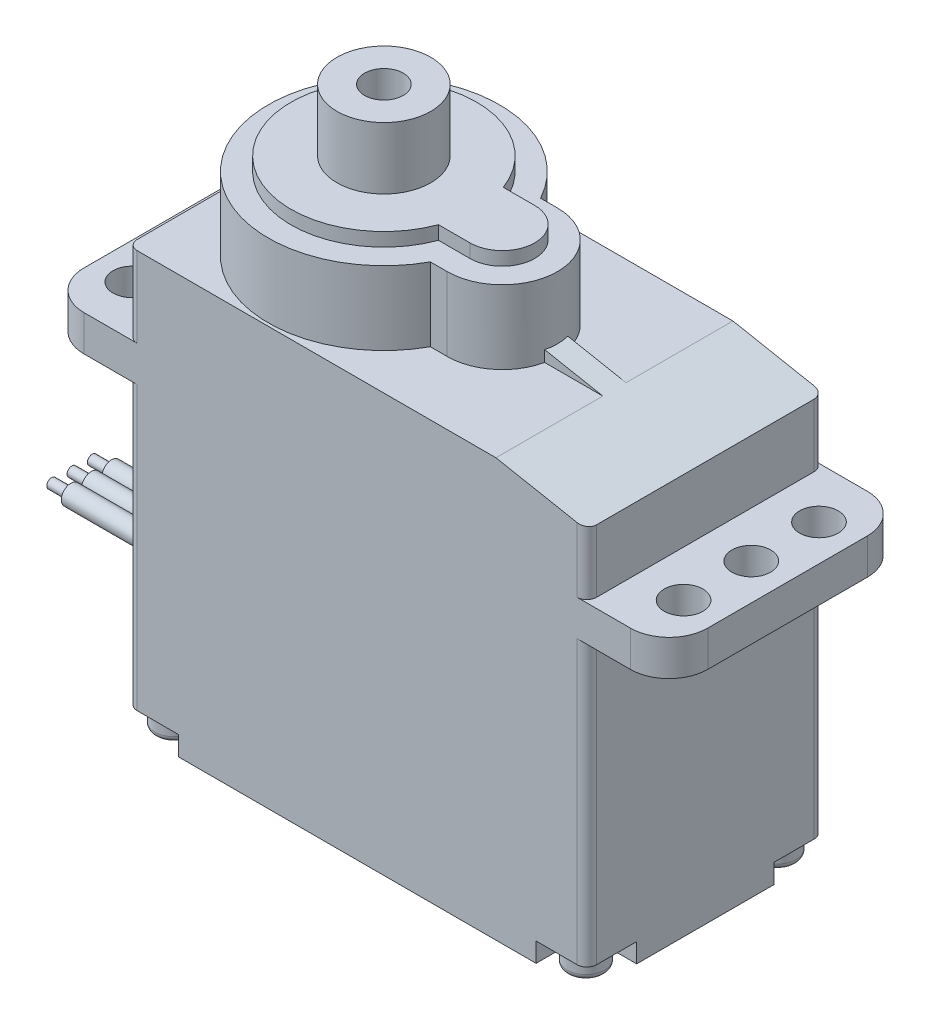
from build123d import *

# Parameters (mm, degrees)
BOSS_EXTRUDE1_DEPTH = 6.125
BOSS_EXTRUDE2_DEPTH = 3.8
BOSS_EXTRUDE3_DEPTH = 0.7
SKETCH4_R           = 1
CUT_EXTRUDE1_DEPTH  = 27.766257209
SKETCH5_R           = 0.975
CUT_EXTRUDE2_DEPTH  = 1
SKETCH6_R           = 0.5
BOSS_EXTRUDE4_DEPTH = 8
SKETCH7_R           = 0.25
BOSS_EXTRUDE5_DEPTH = 1
BOSS_EXTRUDE6_DEPTH = 0.6
SKETCH9_W           = 1.425
SKETCH9_H           = 3.2
FILLET1_R           = 0.3
FILLET2_R           = 2
FILLET3_R           = 0.5


with BuildPart() as part:
    # Sketch1 → Boss-Extrude1 (new, symmetric)
    with BuildSketch(Plane.XY):
        Polygon((-7.13, 6), (11.92, 6), (16.62, 5.1), (16.62, 1.85), (20.87, 1.85), (20.87, 0), (16.62, 0), (16.62, -15.6), (-7.13, -15.6), (-7.13, 0), (-11.38, 0), (-11.38, 1.85), (-7.13, 1.85), align=None)
    extrude(amount=BOSS_EXTRUDE1_DEPTH, both=True)

    # Sketch2 → Boss-Extrude2 (add)
    with BuildSketch(Plane(origin=(0, 6, 0), x_dir=(1, 0, 0), z_dir=(0, 1, 0))):
        with BuildLine():
            Line((5.251487884, -2.85), (6.125, -2.85))
            ThreePointArc((6.125, -2.85), (8.975, 0), (6.125, 2.85))
            Line((6.125, 2.85), (5.251487884, 2.85))
            ThreePointArc((5.251487884, 2.85), (-5.975, 0), (5.251487884, -2.85))
        make_face()
    extrude(amount=BOSS_EXTRUDE2_DEPTH)

    # Sketch3 → Boss-Extrude3 (add)
    with BuildSketch(Plane(origin=(0, 9.8, 0), x_dir=(1, 0, 0), z_dir=(0, 1, 0))):
        with BuildLine():
            Line((4.498263554, -1.675), (6.125, -1.675))
            ThreePointArc((6.125, -1.675), (7.8, 0), (6.125, 1.675))
            Line((6.125, 1.675), (4.498263554, 1.675))
            ThreePointArc((4.498263554, 1.675), (-4.8, 0), (4.498263554, -1.675))
        make_face()
    extrude(amount=BOSS_EXTRUDE3_DEPTH)

    # Sketch4 → Cut-Extrude1 (cut, through all)
    with BuildSketch(Plane(origin=(0, 0, 0), x_dir=(1, 0, 0), z_dir=(0, 1, 0))):
        with Locations((-9.505, 3.5)):
            Circle(SKETCH4_R)
        with Locations((-9.505, -3.5)):
            Circle(SKETCH4_R)
        with Locations((18.995, 3.5)):
            Circle(SKETCH4_R)
        with Locations((18.995, -3.5)):
            Circle(SKETCH4_R)
        with Locations((18.995, 0)):
            Circle(SKETCH4_R)
        with Locations((-9.505, 0)):
            Circle(SKETCH4_R)
    extrude(amount=CUT_EXTRUDE1_DEPTH, mode=Mode.SUBTRACT)

    # Sketch5 → Cut-Extrude2 (cut)
    # profile 1 of 4: a face of its own
    with BuildSketch(Plane.XZ.offset(15.6)):
        with BuildLine():
            Line((16.62, 6.125), (13.995, 6.125))
            Line((13.995, 6.125), (13.995, 4.85))
            ThreePointArc((13.995, 4.85), (14.375761184, 3.930761184), (15.295, 3.55))
            Line((15.295, 3.55), (16.62, 3.55))
            Line((16.62, 3.55), (16.62, 6.125))
        make_face()
        with Locations((15.395, 4.95)):
            Circle(SKETCH5_R, mode=Mode.SUBTRACT)
    # profile 2 of 4: a face of its own
    with BuildSketch(Plane.XZ.offset(15.6)):
        with BuildLine():
            Line((16.62, -6.125), (13.995, -6.125))
            Line((13.995, -6.125), (13.995, -4.85))
            ThreePointArc((13.995, -4.85), (14.375761184, -3.930761184), (15.295, -3.55))
            Line((15.295, -3.55), (16.62, -3.55))
            Line((16.62, -3.55), (16.62, -6.125))
        make_face()
        with Locations((15.395, -4.95)):
            Circle(SKETCH5_R, mode=Mode.SUBTRACT)
    # profile 3 of 4: a face of its own
    with BuildSketch(Plane.XZ.offset(15.6)):
        with BuildLine():
            Line((-7.13, 6.125), (-4.505, 6.125))
            Line((-4.505, 6.125), (-4.505, 4.85))
            ThreePointArc((-4.505, 4.85), (-4.885761184, 3.930761184), (-5.805, 3.55))
            Line((-5.805, 3.55), (-7.13, 3.55))
            Line((-7.13, 3.55), (-7.13, 6.125))
        make_face()
        with Locations((-5.905, 4.95)):
            Circle(SKETCH5_R, mode=Mode.SUBTRACT)
    # profile 4 of 4: a face of its own
    with BuildSketch(Plane.XZ.offset(15.6)):
        with BuildLine():
            Line((-7.13, -6.125), (-4.505, -6.125))
            Line((-4.505, -6.125), (-4.505, -4.85))
            ThreePointArc((-4.505, -4.85), (-4.885761184, -3.930761184), (-5.805, -3.55))
            Line((-5.805, -3.55), (-7.13, -3.55))
            Line((-7.13, -3.55), (-7.13, -6.125))
        make_face()
        with Locations((-5.905, -4.95)):
            Circle(SKETCH5_R, mode=Mode.SUBTRACT)
    extrude(amount=-CUT_EXTRUDE2_DEPTH, mode=Mode.SUBTRACT)

    # Sketch6 → Boss-Extrude4 (add)
    with BuildSketch(Plane.ZY.offset(7.13)):
        with Locations((0, -11.7)):
            Circle(SKETCH6_R)
        with Locations((1.05, -11.7)):
            Circle(SKETCH6_R)
        with Locations((-1.05, -11.7)):
            Circle(SKETCH6_R)
    extrude(amount=BOSS_EXTRUDE4_DEPTH)

    # Sketch7 → Boss-Extrude5 (add)
    with BuildSketch(Plane.ZY.offset(15.13)):
        with Locations((0, -11.7)):
            Circle(SKETCH7_R)
        with Locations((1.05, -11.7)):
            Circle(SKETCH7_R)
        with Locations((-1.05, -11.7)):
            Circle(SKETCH7_R)
    extrude(amount=BOSS_EXTRUDE5_DEPTH)

    # Sketch8 → Boss-Extrude6 (add, symmetric)
    with BuildSketch(Plane.XY):
        Polygon((11.92, 6), (7.8, 6.78893617), (7.8, 6), align=None)
    extrude(amount=BOSS_EXTRUDE6_DEPTH, both=True)

    # Sketch9 → Revolve1 (revolve)
    with BuildSketch(Plane.XY):
        with Locations((1.7125, 12.1)):
            Rectangle(SKETCH9_W, SKETCH9_H)
    revolve(axis=Axis((0, 55, 0), (0, -1, 0)))

    # Fillet1
    fillet1_edges = [part.edges().sort_by_distance(p)[0] for p in [
        (14.42, -15.6, -4.95),
        (14.42, -15.6, 4.95),
        (-6.88, -15.6, -4.95),
        (-6.88, -15.6, 4.95),
    ]]
    fillet(fillet1_edges, radius=FILLET1_R)

    # Fillet2
    fillet2_edges = [part.edges().sort_by_distance(p)[0] for p in [
        (20.87, 0.925, -6.125),
        (20.87, 0.925, 6.125),
        (-11.38, 0.925, 6.125),
        (-11.38, 0.925, -6.125),
    ]]
    fillet(fillet2_edges, radius=FILLET2_R)

    # Fillet3
    fillet3_edges = [part.edges().sort_by_distance(p)[0] for p in [
        (16.62, -7.3, -6.125),
        (16.62, 3.475, -6.125),
        (16.62, 3.475, 6.125),
        (16.62, -7.3, 6.125),
        (-7.13, -7.3, -6.125),
        (-7.13, 3.925, -6.125),
        (-7.13, 3.925, 6.125),
        (-7.13, -7.3, 6.125),
    ]]
    fillet(fillet3_edges, radius=FILLET3_R)


solid = part.part
